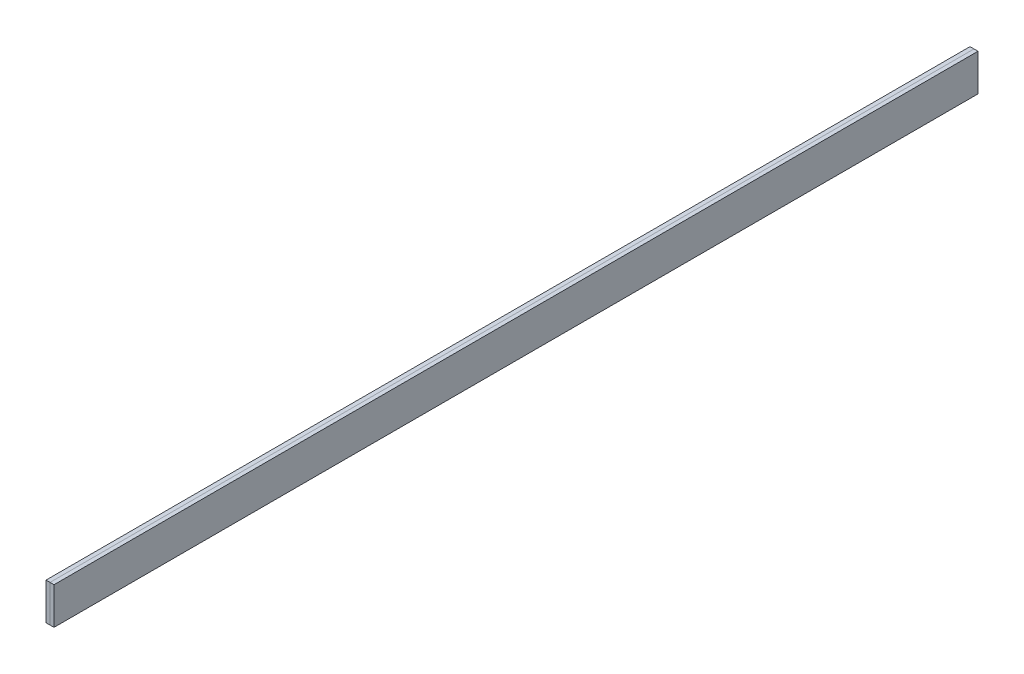
from build123d import *

# Parameters (mm, degrees)
SKETCH1_W           = 0.65
SKETCH1_H           = 6
BOSS_EXTRUDE1_DEPTH = 150


with BuildPart() as part:
    # Sketch1 → Boss-Extrude1 (new body)
    with BuildSketch(Plane.XY):
        with Locations((-0.325, 3)):
            Rectangle(SKETCH1_W, SKETCH1_H)
    extrude(amount=BOSS_EXTRUDE1_DEPTH)


with BuildPart() as body_2:
    # Mirror2: mirrored copy
    add(part.part.mirror(Plane(origin=(0, 0, 150), x_dir=(0, 0, 1), z_dir=(-1, 0, 0))))


solid = Compound([part.part, body_2.part])
